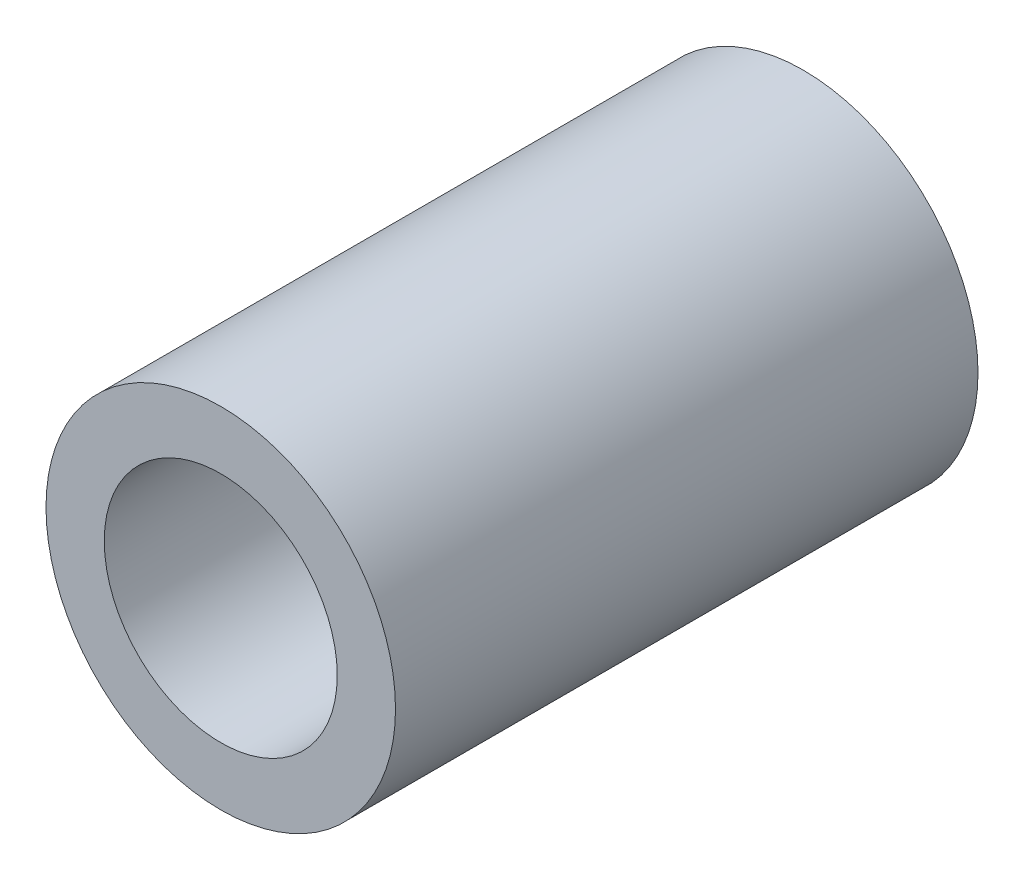
from build123d import *

# Parameters (mm, degrees)
ESQUISSE1_R        = 6
ESQUISSE1_R_2      = 4
BOSS_EXTRU_1_DEPTH = 20


with BuildPart() as part:
    # Esquisse1 → Boss.-Extru.1 (new body)
    with BuildSketch(Plane.XY):
        Circle(ESQUISSE1_R)
        Circle(ESQUISSE1_R_2, mode=Mode.SUBTRACT)
    extrude(amount=BOSS_EXTRU_1_DEPTH)


solid = part.part
